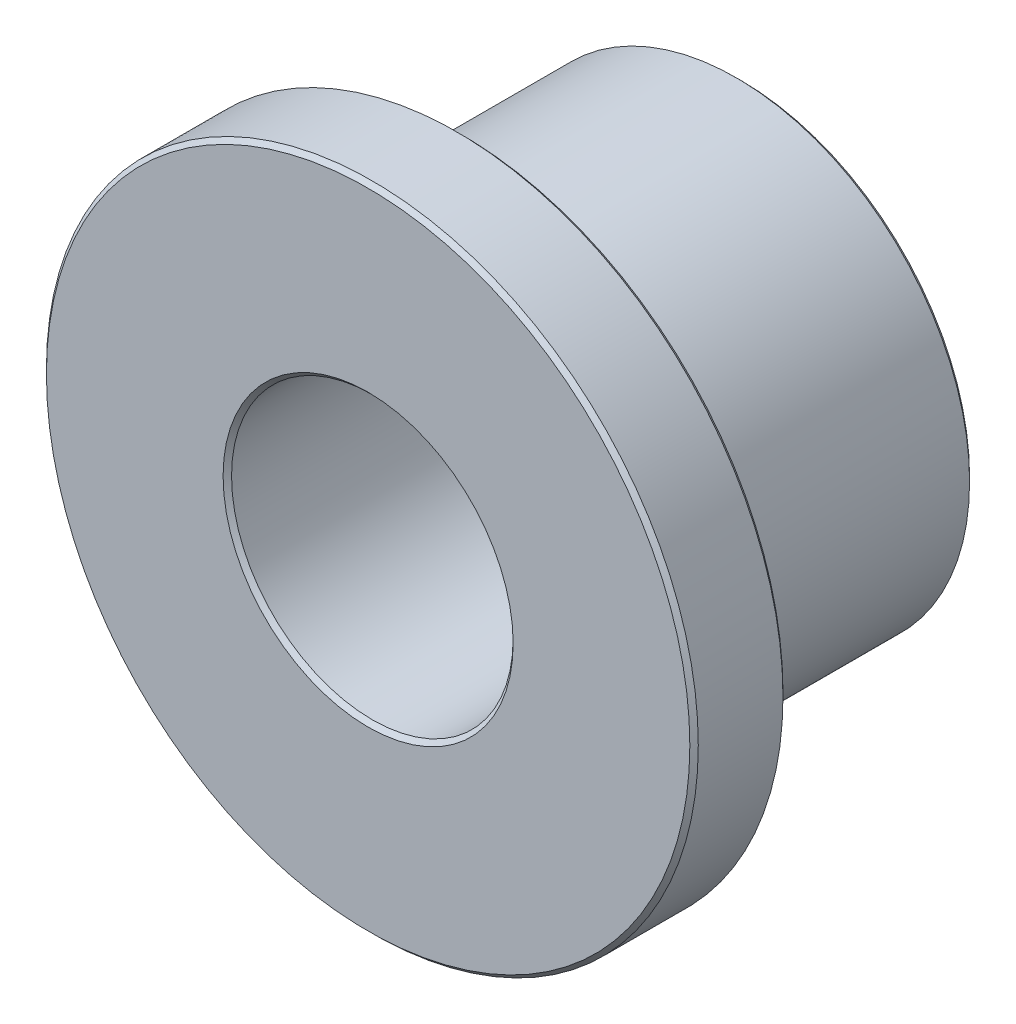
from build123d import *

# Parameters (mm, degrees)
BOSS_EXTRUDE1_START = 3.175
SKETCH3_R           = 5.55625
SKETCH3_R_2         = 2.4003
BOSS_EXTRUDE1_DEPTH = 1.5875
BOSS_EXTRUDE2_START = 1.5875
SKETCH4_R           = 3.9751
SKETCH4_R_2         = 2.4003
BOSS_EXTRUDE2_DEPTH = 4.7625
CHAMFER1_SIZE       = 0.072009


with BuildPart() as part:
    # Sketch3 → Boss-Extrude1 (new body)
    with BuildSketch(Plane.XY.offset(BOSS_EXTRUDE1_START)):
        Circle(SKETCH3_R)
        Circle(SKETCH3_R_2, mode=Mode.SUBTRACT)
    extrude(amount=-BOSS_EXTRUDE1_DEPTH)

    # Sketch4 → Boss-Extrude2 (add)
    with BuildSketch(Plane.XY.offset(BOSS_EXTRUDE2_START)):
        Circle(SKETCH4_R)
        Circle(SKETCH4_R_2, mode=Mode.SUBTRACT)
    extrude(amount=-BOSS_EXTRUDE2_DEPTH)

    # Chamfer1
    chamfer1_edges = [part.edges().sort_by_distance(p)[0] for p in [
        (-2.4003, 0, -3.175),
        (-3.9751, 0, 1.5875),
        (-5.55625, 0, 3.175),
        (-5.55625, 0, 1.5875),
        (-2.4003, 0, 3.175),
        (-3.9751, 0, -3.175),
    ]]
    chamfer(chamfer1_edges, length=CHAMFER1_SIZE)


solid = part.part
